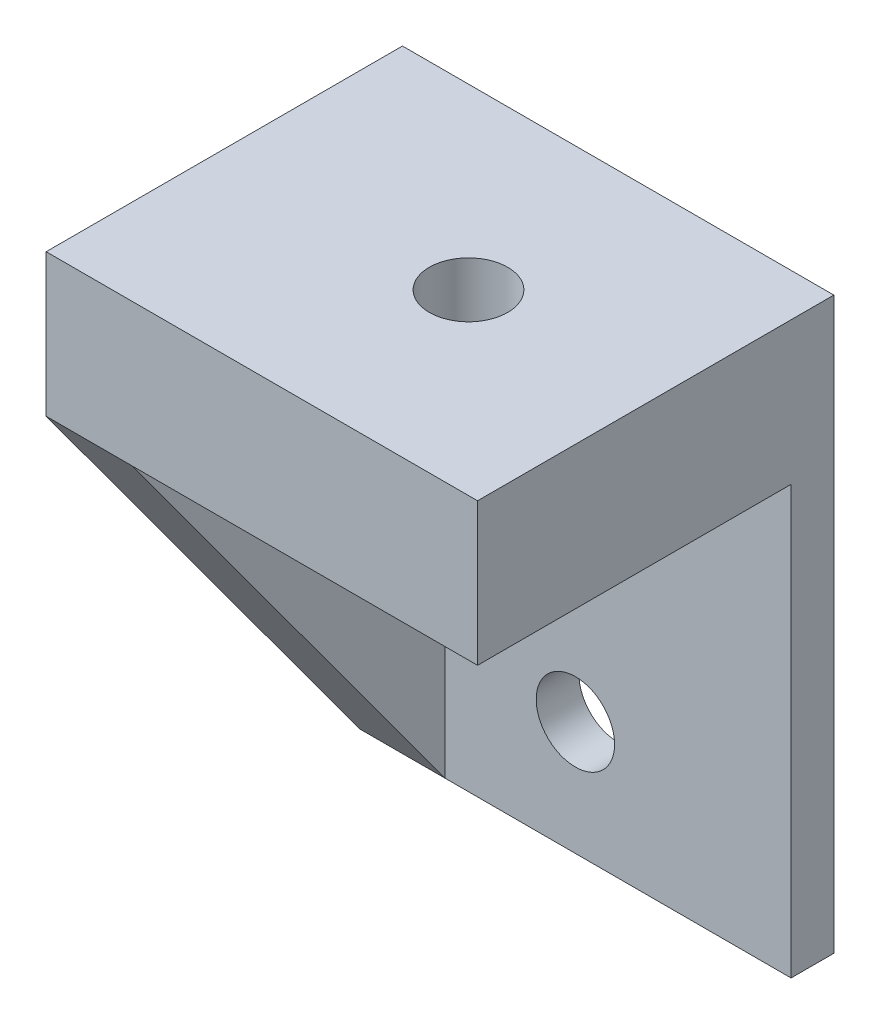
from build123d import *

# Parameters (mm, degrees)
SKETCH1_W           = 15.135
SKETCH1_H           = 12.5
BASE_DEPTH          = 5
SKETCH2_W           = 15.135
SKETCH2_H           = 15
BOSS_EXTRUDE2_DEPTH = 1.5
BOSS_EXTRUDE3_DEPTH = 15.135
SKETCH4_W           = 9.135
SKETCH4_H           = 15
CUT_EXTRUDE1_DEPTH  = 11
SKETCH5_R           = 1.375
CUT_EXTRUDE2_DEPTH  = 2
SKETCH6_R           = 1.375
CUT_EXTRUDE3_DEPTH  = 5.75
CUT_EXTRUDE4_DEPTH  = 10


with BuildPart() as part:
    # Sketch1 → base (new body)
    with BuildSketch(Plane(origin=(0, 0, 0), x_dir=(1, 0, 0), z_dir=(0, 1, 0))):
        with Locations((7.5675, 6.25)):
            Rectangle(SKETCH1_W, SKETCH1_H)
    extrude(amount=BASE_DEPTH)

    # Sketch2 → Boss-Extrude2 (add)
    with BuildSketch(Plane(origin=(0, 0, -12.5), x_dir=(-1, 0, 0), z_dir=(0, 0, -1))):
        with Locations((-7.5675, -7.5)):
            Rectangle(SKETCH2_W, SKETCH2_H)
    extrude(amount=-BOSS_EXTRUDE2_DEPTH)

    # Sketch3 → Boss-Extrude3 (add)
    with BuildSketch(Plane.ZY):
        Polygon((0, 0), (-11, -15), (-11, 0), align=None)
    extrude(amount=-BOSS_EXTRUDE3_DEPTH)

    # Sketch4 → Cut-Extrude1 (cut)
    with BuildSketch(Plane.XY):
        with Locations((7.5675, -7.5)):
            Rectangle(SKETCH4_W, SKETCH4_H)
    extrude(amount=-CUT_EXTRUDE1_DEPTH, mode=Mode.SUBTRACT)

    # Sketch5 → Cut-Extrude2 (cut)
    with BuildSketch(Plane.XY.offset(-11)):
        with Locations((7.5675, -4)):
            Circle(SKETCH5_R)
        with Locations((7.5675, -11)):
            Circle(SKETCH5_R)
    extrude(amount=-CUT_EXTRUDE2_DEPTH, mode=Mode.SUBTRACT)

    # Sketch6 → Cut-Extrude3 (cut)
    with BuildSketch(Plane(origin=(0, 5, 0), x_dir=(1, 0, 0), z_dir=(0, 1, 0))):
        with Locations((8.5675, 6.25)):
            Circle(SKETCH6_R)
    extrude(amount=-CUT_EXTRUDE3_DEPTH, mode=Mode.SUBTRACT)

    # Sketch7 → Cut-Extrude4 (cut)
    with BuildSketch(Plane.ZY.offset(-12.135)):
        Polygon((-11, -15), (0, 0), (-11, 0), align=None)
    extrude(amount=-CUT_EXTRUDE4_DEPTH, mode=Mode.SUBTRACT)


solid = part.part
